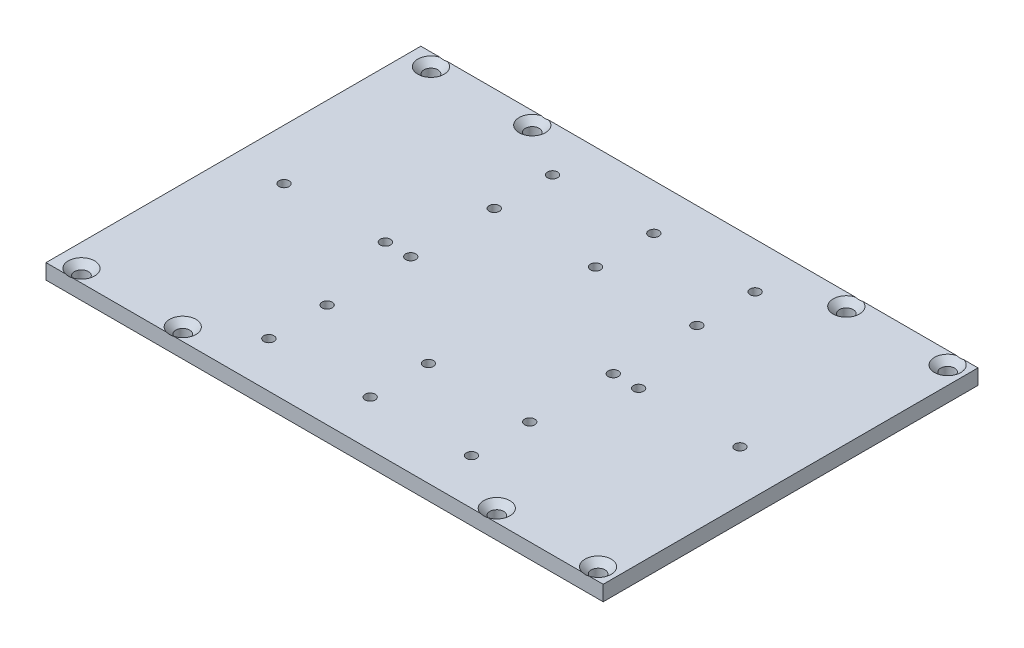
from build123d import *

# Parameters (mm, degrees)
SKETCH1_W                                       = 220
SKETCH1_H                                       = 148
BOSS_EXTRUDE1_DEPTH                             = 6
CSK_FOR_M5_FLAT_HEAD_MACHINE_SCREW2_D           = 5.5
CSK_FOR_M5_FLAT_HEAD_MACHINE_SCREW2_CSINK_D     = 10.4
CSK_FOR_M5_FLAT_HEAD_MACHINE_SCREW2_CSINK_ANGLE = 90
F_4_0MM_DOWEL_HOLE1_D                           = 4
F_4_0MM_DOWEL_HOLE1_DEPTH                       = 12
F_4_0MM_DOWEL_HOLE1_TIP                         = 1.201721238
F_4_0MM_DOWEL_HOLE2_AT_2_COUNT                  = 2
F_4_0MM_DOWEL_HOLE2_AT_2_PITCH                  = 23
F_4_0MM_DOWEL_HOLE2_AT_3_COUNT                  = 2
F_4_0MM_DOWEL_HOLE2_AT_3_PITCH                  = 33
F_4_0MM_DOWEL_HOLE2_AT_4_COUNT                  = 2
F_4_0MM_DOWEL_HOLE2_AT_4_PITCH                  = 34.481879299
F_4_0MM_DOWEL_HOLE2_AT_5_COUNT                  = 2
F_4_0MM_DOWEL_HOLE2_AT_5_PITCH                  = 59.908263203
F_4_0MM_DOWEL_HOLE2_AT_6_COUNT                  = 2
F_4_0MM_DOWEL_HOLE2_AT_6_PITCH                  = 89
F_4_0MM_DOWEL_HOLE2_AT_7_COUNT                  = 2
F_4_0MM_DOWEL_HOLE2_AT_7_PITCH                  = 66


with BuildPart() as part:
    # Sketch1 → Boss-Extrude1 (new body)
    with BuildSketch(Plane(origin=(0, 0, 0), x_dir=(1, 0, 0), z_dir=(0, 1, 0))):
        Rectangle(SKETCH1_W, SKETCH1_H)
    extrude(amount=BOSS_EXTRUDE1_DEPTH)

    # CSK for M5 Flat Head Machine Screw2 (through all)
    with Locations(Plane(origin=(0, 6, 0), x_dir=(1, 0, 0), z_dir=(0, 1, 0))):
        with Locations((103, -69), (63, -69), (-101, -69), (-61, -69), (103, 69), (63, 69), (-61, 69), (-101, 69)):
            CounterSinkHole(CSK_FOR_M5_FLAT_HEAD_MACHINE_SCREW2_D / 2, CSK_FOR_M5_FLAT_HEAD_MACHINE_SCREW2_CSINK_D / 2, counter_sink_angle=CSK_FOR_M5_FLAT_HEAD_MACHINE_SCREW2_CSINK_ANGLE)

    # Ø4.0mm Dowel Hole1
    with Locations(Plane(origin=(0, 6, 0), x_dir=(1, 0, 0), z_dir=(0, 1, 0))):
        with Locations((0, 56), (0, 33), (0, -33), (0, -56)):
            Hole(F_4_0MM_DOWEL_HOLE1_D / 2, depth=F_4_0MM_DOWEL_HOLE1_DEPTH)
            with Locations((0, 0, -(F_4_0MM_DOWEL_HOLE1_DEPTH + F_4_0MM_DOWEL_HOLE1_TIP / 2))):  # 118° drill point
                Cone(0, F_4_0MM_DOWEL_HOLE1_D / 2, F_4_0MM_DOWEL_HOLE1_TIP, mode=Mode.SUBTRACT)

    # Sketch8 → Ø4.0mm Dowel Hole2 (revolve, cut)
    with BuildSketch(Plane(origin=(-40, 6, -33), x_dir=(0, 0, 1), z_dir=(1, 0, 0))):
        Polygon((0, 0), (0, 13.201721238), (2, 12), (2, 0), align=None)
    f_4_0mm_dowel_hole2 = revolve(axis=Axis((-40, 12.35, -33), (0, -1, 0)), mode=Mode.SUBTRACT)

    # Ø4.0mm Dowel Hole2 at 2: Ø4.0mm Dowel Hole2 ×2
    with Locations(*[(0, 0, -i * F_4_0MM_DOWEL_HOLE2_AT_2_PITCH) for i in range(1, F_4_0MM_DOWEL_HOLE2_AT_2_COUNT)]):
        add(f_4_0mm_dowel_hole2, mode=Mode.SUBTRACT)

    # Ø4.0mm Dowel Hole2 at 3: Ø4.0mm Dowel Hole2 ×2
    with Locations(*[(0, 0, i * F_4_0MM_DOWEL_HOLE2_AT_3_PITCH) for i in range(1, F_4_0MM_DOWEL_HOLE2_AT_3_COUNT)]):
        add(f_4_0mm_dowel_hole2, mode=Mode.SUBTRACT)

    # Ø4.0mm Dowel Hole2 at 4: Ø4.0mm Dowel Hole2 ×2
    with Locations(*[Vector(-0.290007395, 0, 0.957024404) * (i * F_4_0MM_DOWEL_HOLE2_AT_4_PITCH) for i in range(1, F_4_0MM_DOWEL_HOLE2_AT_4_COUNT)]):
        add(f_4_0mm_dowel_hole2, mode=Mode.SUBTRACT)

    # Ø4.0mm Dowel Hole2 at 5: Ø4.0mm Dowel Hole2 ×2
    with Locations(*[Vector(-0.834609407, 0, 0.550842208) * (i * F_4_0MM_DOWEL_HOLE2_AT_5_PITCH) for i in range(1, F_4_0MM_DOWEL_HOLE2_AT_5_COUNT)]):
        add(f_4_0mm_dowel_hole2, mode=Mode.SUBTRACT)

    # Ø4.0mm Dowel Hole2 at 6: Ø4.0mm Dowel Hole2 ×2
    with Locations(*[(0, 0, i * F_4_0MM_DOWEL_HOLE2_AT_6_PITCH) for i in range(1, F_4_0MM_DOWEL_HOLE2_AT_6_COUNT)]):
        add(f_4_0mm_dowel_hole2, mode=Mode.SUBTRACT)

    # Ø4.0mm Dowel Hole2 at 7: Ø4.0mm Dowel Hole2 ×2
    with Locations(*[(0, 0, i * F_4_0MM_DOWEL_HOLE2_AT_7_PITCH) for i in range(1, F_4_0MM_DOWEL_HOLE2_AT_7_COUNT)]):
        add(f_4_0mm_dowel_hole2, mode=Mode.SUBTRACT)

    # Mirror1: Ø4.0mm Dowel Hole2 across plane
    add(f_4_0mm_dowel_hole2.mirror(Plane(origin=(0, 0, 0), x_dir=(0, 0, 1), z_dir=(1, 0, 0))), mode=Mode.SUBTRACT)

    # Mirror1 copy 1 sketch → Mirror1 copy 1 (revolve, cut)
    with BuildSketch(Plane(origin=(40, 6, -56), x_dir=(0, 0, 1), z_dir=(-1, 0, 0))):
        Polygon((0, 0), (0, -13.201721238), (2, -12), (2, 0), align=None)
    revolve(axis=Axis((40, 12.35, -56), (0, 1, 0)), mode=Mode.SUBTRACT)

    # Mirror1 copy 2 sketch → Mirror1 copy 2 (revolve, cut)
    with BuildSketch(Plane(origin=(40, 6, 0), x_dir=(0, 0, 1), z_dir=(-1, 0, 0))):
        Polygon((0, 0), (0, -13.201721238), (2, -12), (2, 0), align=None)
    revolve(axis=Axis((40, 12.35, 0), (0, 1, 0)), mode=Mode.SUBTRACT)

    # Mirror1 copy 3 sketch → Mirror1 copy 3 (revolve, cut)
    with BuildSketch(Plane(origin=(50, 6, 0), x_dir=(0, 0, 1), z_dir=(-1, 0, 0))):
        Polygon((0, 0), (0, -13.201721238), (2, -12), (2, 0), align=None)
    revolve(axis=Axis((50, 12.35, 0), (0, 1, 0)), mode=Mode.SUBTRACT)

    # Mirror1 copy 4 sketch → Mirror1 copy 4 (revolve, cut)
    with BuildSketch(Plane(origin=(90, 6, 0), x_dir=(0, 0, 1), z_dir=(-1, 0, 0))):
        Polygon((0, 0), (0, -13.201721238), (2, -12), (2, 0), align=None)
    revolve(axis=Axis((90, 12.35, 0), (0, 1, 0)), mode=Mode.SUBTRACT)

    # Mirror1 copy 5 sketch → Mirror1 copy 5 (revolve, cut)
    with BuildSketch(Plane(origin=(40, 6, 56), x_dir=(0, 0, 1), z_dir=(-1, 0, 0))):
        Polygon((0, 0), (0, -13.201721238), (2, -12), (2, 0), align=None)
    revolve(axis=Axis((40, 12.35, 56), (0, 1, 0)), mode=Mode.SUBTRACT)

    # Mirror1 copy 6 sketch → Mirror1 copy 6 (revolve, cut)
    with BuildSketch(Plane(origin=(40, 6, 33), x_dir=(0, 0, 1), z_dir=(-1, 0, 0))):
        Polygon((0, 0), (0, -13.201721238), (2, -12), (2, 0), align=None)
    revolve(axis=Axis((40, 12.35, 33), (0, 1, 0)), mode=Mode.SUBTRACT)


solid = part.part
